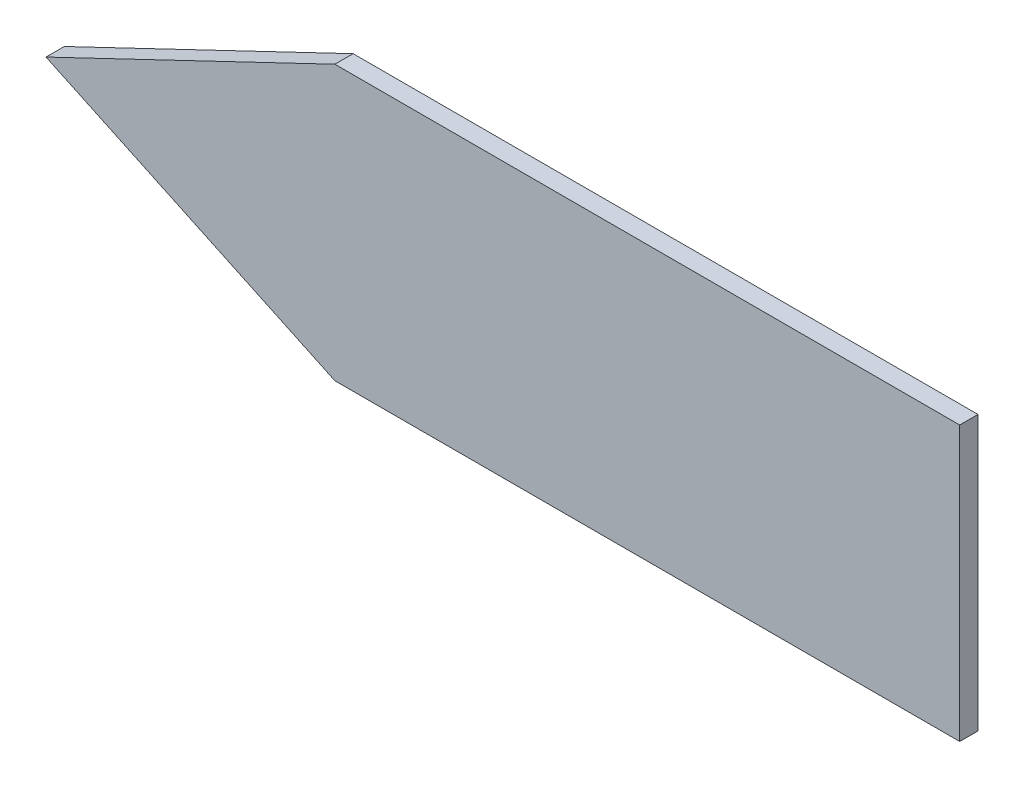
from build123d import *

# Parameters (mm, degrees)
RESSALTO_EXTRUS_O1_DEPTH = 1


with BuildPart() as part:
    # Esboço1 → Ressalto-extrusão1 (new body)
    with BuildSketch(Plane.XY):
        Polygon((15.806890347, -7.436944525), (50, -7.436944525), (50, 7.563055475), (15.806890347, 7.563055475), (0, 0), align=None)
    extrude(amount=RESSALTO_EXTRUS_O1_DEPTH)


solid = part.part
